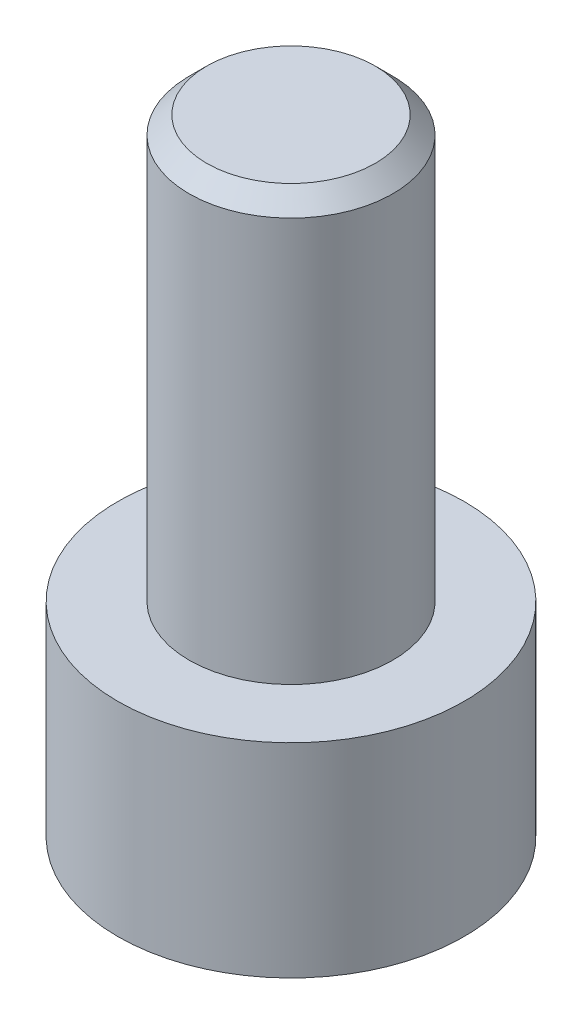
from build123d import *

# Parameters (mm, degrees)
SKETCH1_R           = 2.465
BOSS_EXTRUDE1_DEPTH = 2.9
SKETCH2_R           = 1.45
BOSS_EXTRUDE2_DEPTH = 6
CUT_EXTRUDE1_DEPTH  = 1.9
CHAMFER1_SIZE       = 0.25


with BuildPart() as part:
    # Sketch1 → Boss-Extrude1 (new body)
    with BuildSketch(Plane(origin=(0, 0, 0), x_dir=(1, 0, 0), z_dir=(0, 1, 0))):
        Circle(SKETCH1_R)
    extrude(amount=BOSS_EXTRUDE1_DEPTH)

    # Sketch2 → Boss-Extrude2 (add)
    with BuildSketch(Plane(origin=(0, 2.9, 0), x_dir=(1, 0, 0), z_dir=(0, 1, 0))):
        Circle(SKETCH2_R)
    extrude(amount=BOSS_EXTRUDE2_DEPTH)

    # Sketch3 → Cut-Extrude1 (cut)
    with BuildSketch(Plane.XZ):
        Polygon((0.733234842, -1.27), (1.466469684, 0), (0.733234842, 1.27), (-0.733234842, 1.27), (-1.466469684, 0), (-0.733234842, -1.27), align=None)
    extrude(amount=-CUT_EXTRUDE1_DEPTH, mode=Mode.SUBTRACT)

    # Chamfer1
    chamfer1_edges = [part.edges().sort_by_distance(p)[0] for p in [
        (-1.45, 8.9, 0),
    ]]
    chamfer(chamfer1_edges, length=CHAMFER1_SIZE)


solid = part.part
